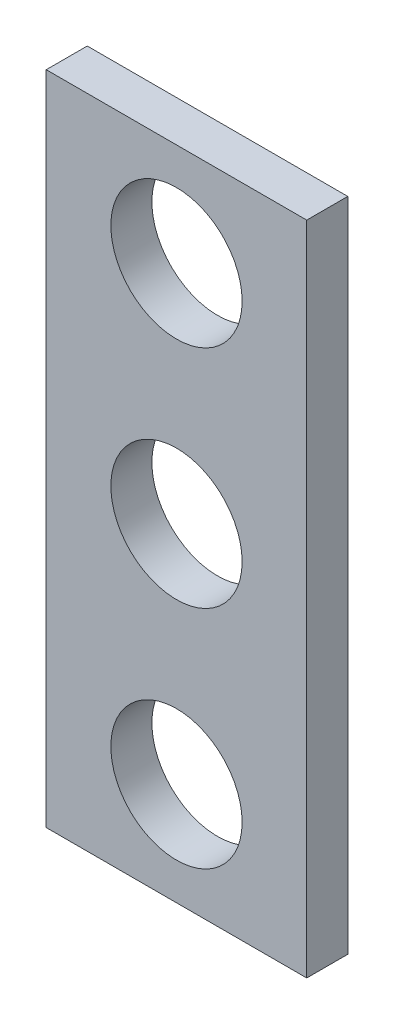
from build123d import *

# Parameters (mm, degrees)
SKETCH1_W           = 6.35
SKETCH1_H           = 16
SKETCH1_R           = 1.6
BOSS_EXTRUDE1_DEPTH = 1


with BuildPart() as part:
    # Sketch1 → Boss-Extrude1 (new body)
    with BuildSketch(Plane.XY):
        with Locations((0, 169.786291501)):
            Rectangle(SKETCH1_W, SKETCH1_H)
        with Locations((0, 169.786291501)):
            Circle(SKETCH1_R, mode=Mode.SUBTRACT)
        with Locations((0, 175.286291501)):
            Circle(SKETCH1_R, mode=Mode.SUBTRACT)
        with Locations((0, 164.286291501)):
            Circle(SKETCH1_R, mode=Mode.SUBTRACT)
    extrude(amount=BOSS_EXTRUDE1_DEPTH)


solid = part.part
